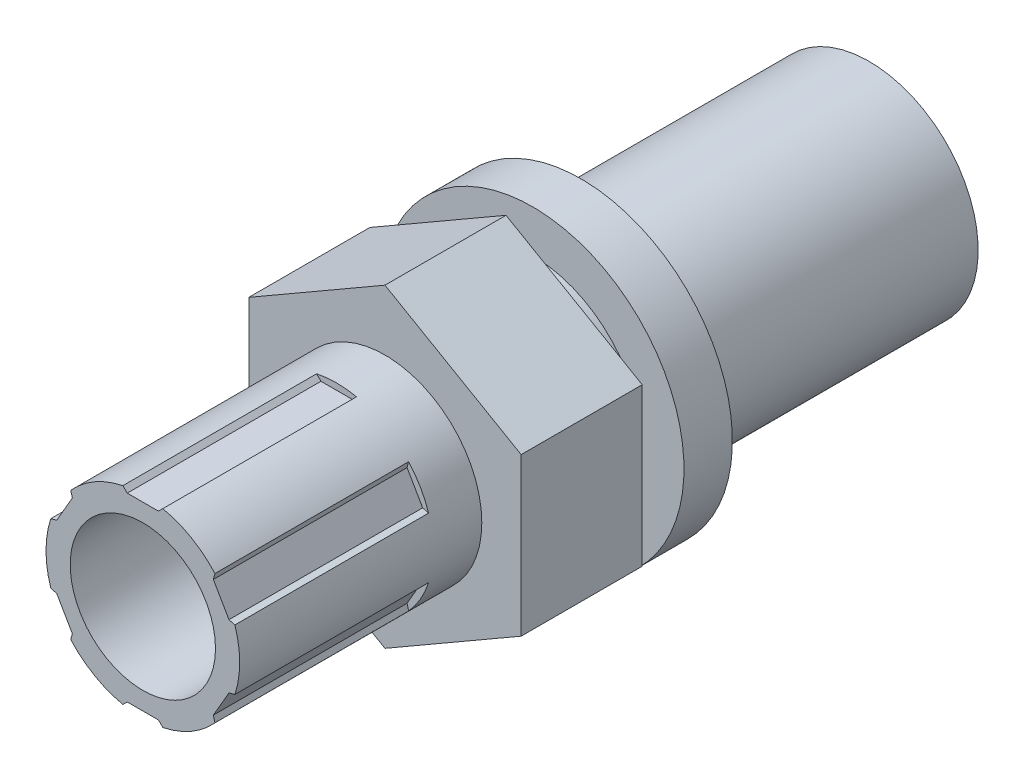
from build123d import *

# Parameters (mm, degrees)
BOSS_EXTRUDE1_DEPTH = 6.35
SKETCH2_R           = 5.08
SKETCH2_R_2         = 3.81
BOSS_EXTRUDE2_DEPTH = 12.7
SKETCH3_R           = 5.715
BOSS_EXTRUDE3_DEPTH = 19.05
SKETCH4_R           = 7.937190451
BOSS_EXTRUDE4_DEPTH = 2.54
SKETCH5_R           = 3.81
CUT_EXTRUDE1_DEPTH  = 26.4
CUT_EXTRUDE2_DEPTH  = 10.16
CIRPATTERN1_COUNT   = 6


with BuildPart() as part:
    # Sketch1 → Boss-Extrude1 (new body)
    with BuildSketch(Plane.XY):
        Polygon((0, 8.248891971), (-7.14375, 4.124445986), (-7.14375, -4.124445986), (0, -8.248891971), (7.14375, -4.124445986), (7.14375, 4.124445986), align=None)
    extrude(amount=BOSS_EXTRUDE1_DEPTH)

    # Sketch2 → Boss-Extrude2 (add)
    with BuildSketch(Plane.XY.offset(6.35)):
        Circle(SKETCH2_R)
        Circle(SKETCH2_R_2, mode=Mode.SUBTRACT)
    extrude(amount=BOSS_EXTRUDE2_DEPTH)

    # Sketch3 → Boss-Extrude3 (add)
    with BuildSketch(Plane(origin=(0, 0, 0), x_dir=(-1, 0, 0), z_dir=(0, 0, -1))):
        Circle(SKETCH3_R)
    extrude(amount=BOSS_EXTRUDE3_DEPTH)

    # Sketch4 → Boss-Extrude4 (add)
    with BuildSketch(Plane(origin=(0, 0, -1.397), x_dir=(-1, 0, 0), z_dir=(0, 0, -1))):
        Circle(SKETCH4_R)
    extrude(amount=BOSS_EXTRUDE4_DEPTH)

    # Sketch5 → Cut-Extrude1 (cut, through all)
    with BuildSketch(Plane.XY.offset(6.35)):
        Circle(SKETCH5_R)
    extrude(amount=-CUT_EXTRUDE1_DEPTH, mode=Mode.SUBTRACT)

    # Sketch6 → Cut-Extrude2 (cut)
    with BuildSketch(Plane.XY.offset(19.05)):
        Polygon((-0.818654099, 4.743933512), (0.818654099, 4.743933512), (1.27, 5.195279413), (-1.27, 5.195279413), align=None)
    cut_extrude2 = extrude(amount=-CUT_EXTRUDE2_DEPTH, mode=Mode.SUBTRACT)

    # CirPattern1: Cut-Extrude2 ×6 about axis
    cirpattern1_axis = Axis((0, 0, 0), (0, 0, 1))
    for i in range(1, CIRPATTERN1_COUNT):
        add(cut_extrude2.rotate(cirpattern1_axis, i * 360 / CIRPATTERN1_COUNT), mode=Mode.SUBTRACT)


solid = part.part
